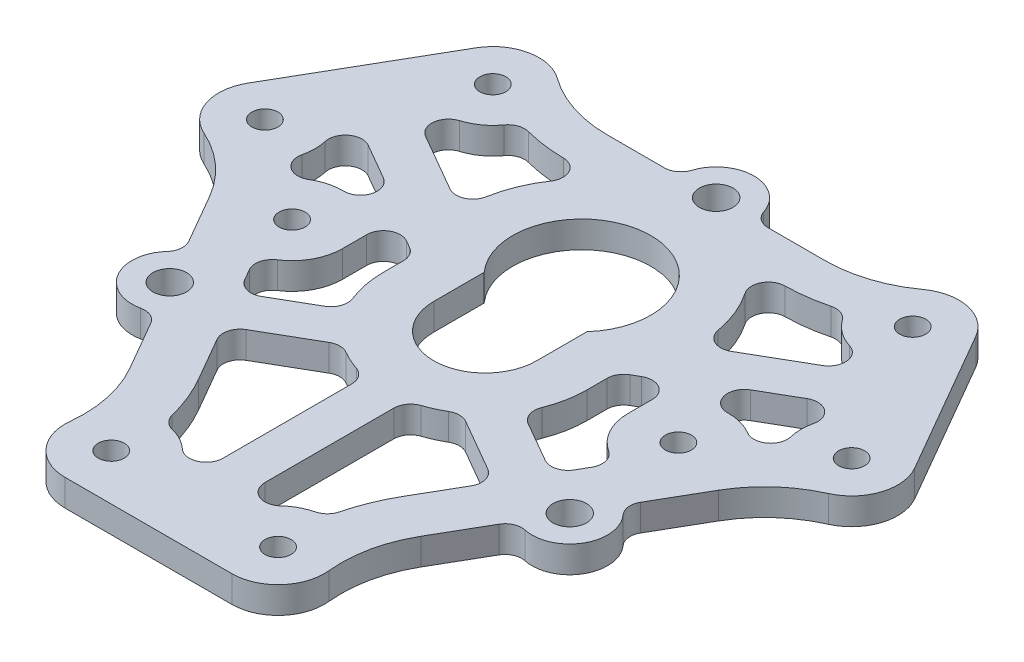
from build123d import *

# Parameters (mm, degrees)
SKETCH1_R           = 1.55
BOSS_EXTRUDE1_DEPTH = 3.175
BOSS_EXTRUDE2_DEPTH = 3.175
SKETCH6_3_R         = 2
CUT_EXTRUDE1_DEPTH  = 3.175
CUT_EXTRUDE2_DEPTH  = 3.175


with BuildPart() as part:
    # Sketch1 → Boss-Extrude1 (new body)
    with BuildSketch(Plane(origin=(0, 0, 0), x_dir=(1, 0, 0), z_dir=(0, 1, 0))):
        with BuildLine():
            Line((12.96622445, 27.5), (-12.96622445, 27.5))
            ThreePointArc((-12.96622445, 27.5), (-17.594676309, 28.231943602), (-21.771426072, 30.356342215))
            ThreePointArc((-21.771426072, 30.356342215), (-26.14607948, 31.282933613), (-29.763139721, 28.653667694))
            Line((-29.763139721, 28.653667694), (-39.696373995, 11.448801248))
            ThreePointArc((-39.696373995, 11.448801248), (-40.164854954, 7.001702233), (-37.17507656, 3.676436947))
            ThreePointArc((-37.17507656, 3.676436947), (-33.246918512, 1.121464854), (-30.298810829, -2.520920235))
            Line((-30.298810829, -2.520920235), (-17.332586379, -24.979079765))
            ThreePointArc((-17.332586379, -24.979079765), (-15.652242203, -29.353408456), (-15.403650488, -34.032779162))
            ThreePointArc((-15.403650488, -34.032779162), (-14.018775474, -38.284635845), (-9.933234274, -40.102468942))
            Line((-9.933234274, -40.102468942), (9.933234274, -40.102468942))
            ThreePointArc((9.933234274, -40.102468942), (14.018775474, -38.284635845), (15.403650488, -34.032779162))
            ThreePointArc((15.403650488, -34.032779162), (15.652242203, -29.353408456), (17.332586379, -24.979079765))
            Line((17.332586379, -24.979079765), (30.298810829, -2.520920235))
            ThreePointArc((30.298810829, -2.520920235), (33.246918512, 1.121464854), (37.17507656, 3.676436947))
            ThreePointArc((37.17507656, 3.676436947), (40.164854954, 7.001702233), (39.696373995, 11.448801248))
            Line((39.696373995, 11.448801248), (29.763139721, 28.653667694))
            ThreePointArc((29.763139721, 28.653667694), (26.14607948, 31.282933613), (21.771426072, 30.356342215))
            ThreePointArc((21.771426072, 30.356342215), (17.594676309, 28.231943602), (12.96622445, 27.5))
        make_face()
        with Locations((-9.933234274, -34.602468942)):
            Circle(SKETCH1_R, mode=Mode.SUBTRACT)
        with Locations((9.933234274, -34.602468942)):
            Circle(SKETCH1_R, mode=Mode.SUBTRACT)
        with Locations((-23, 0)):
            Circle(SKETCH1_R, mode=Mode.SUBTRACT)
        with Locations((-34.933234274, 8.698801248)):
            Circle(SKETCH1_R, mode=Mode.SUBTRACT)
        with BuildLine():
            ThreePointArc((6.125, 0), (0, -6.125), (-6.125, 0))
            Line((-6.125, 0), (-6.125, 6))
            ThreePointArc((-6.125, 6), (0, 19.714535499), (6.125, 6))
            Line((6.125, 6), (6.125, 0))
        make_face(mode=Mode.SUBTRACT)
        with Locations((-25, 25.903667694)):
            Circle(SKETCH1_R, mode=Mode.SUBTRACT)
        with Locations((23, 0)):
            Circle(SKETCH1_R, mode=Mode.SUBTRACT)
        with Locations((34.933234274, 8.698801248)):
            Circle(SKETCH1_R, mode=Mode.SUBTRACT)
        with Locations((25, 25.903667694)):
            Circle(SKETCH1_R, mode=Mode.SUBTRACT)
    extrude(amount=BOSS_EXTRUDE1_DEPTH)

    # Sketch6 → Boss-Extrude2 (add)
    with BuildSketch(Plane(origin=(0, 3.175, 0), x_dir=(1, 0, 0), z_dir=(0, 1, 0))):
        with BuildLine():
            ThreePointArc((-2, 27.5), (0, 29.5), (2, 27.5))
            Line((2, 27.5), (6.184658438, 27.5))
            ThreePointArc((6.184658438, 27.5), (5.007961628, 27.88278492), (4.281686611, 28.884615385))
            ThreePointArc((4.281686611, 28.884615385), (0, 32), (-4.281686611, 28.884615385))
            ThreePointArc((-4.281686611, 28.884615385), (-5.007961628, 27.88278492), (-6.184658438, 27.5))
            Line((-6.184658438, 27.5), (-2, 27.5))
        make_face()
        with BuildLine():
            ThreePointArc((-22.815698604, -15.482050808), (-25.547749412, -14.75), (-24.815698604, -12.017949192))
            Line((-24.815698604, -12.017949192), (-26.908027823, -8.393928679))
            ThreePointArc((-26.908027823, -8.393928679), (-26.651180883, -9.604370469), (-27.155654007, -10.734258316))
            ThreePointArc((-27.155654007, -10.734258316), (-27.712812921, -16), (-22.873967396, -18.150357069))
            ThreePointArc((-22.873967396, -18.150357069), (-21.643219255, -18.278414451), (-20.723369385, -19.106071321))
            Line((-20.723369385, -19.106071321), (-22.815698604, -15.482050808))
        make_face()
        with BuildLine():
            ThreePointArc((25.815698604, -13.75), (24.815698604, -15.482050808), (22.815698604, -15.482050808))
            Line((22.815698604, -15.482050808), (20.723369385, -19.106071321))
            ThreePointArc((20.723369385, -19.106071321), (21.643219255, -18.278414451), (22.873967396, -18.150357069))
            ThreePointArc((22.873967396, -18.150357069), (27.712812921, -16), (27.155654007, -10.734258316))
            ThreePointArc((27.155654007, -10.734258316), (26.651180883, -9.604370469), (26.908027823, -8.393928679))
            Line((26.908027823, -8.393928679), (24.815698604, -12.017949192))
            ThreePointArc((24.815698604, -12.017949192), (25.547749412, -12.75), (25.815698604, -13.75))
        make_face()
    extrude(amount=-BOSS_EXTRUDE2_DEPTH)

    # Sketch6_3 → Cut-Extrude1 (cut)
    with BuildSketch(Plane(origin=(0, 3.175, 0), x_dir=(1, 0, 0), z_dir=(0, 1, 0))):
        with Locations((0, 27.5)):
            Circle(SKETCH6_3_R)
        with Locations((23.815698604, -13.75)):
            Circle(SKETCH6_3_R)
        with Locations((-23.815698604, -13.75)):
            Circle(SKETCH6_3_R)
    extrude(amount=-CUT_EXTRUDE1_DEPTH, mode=Mode.SUBTRACT)

    # Sketch8 → Cut-Extrude2 (cut)
    with BuildSketch(Plane(origin=(0, 3.175, 0), x_dir=(1, 0, 0), z_dir=(0, 1, 0))):
        with BuildLine():
            ThreePointArc((-18.014934082, 23.14772543), (-15.625926996, 22.677639334), (-13.197500885, 22.501337264))
            ThreePointArc((-13.197500885, 22.501337264), (-11.44706524, 21.425848219), (-11.568049963, 19.374979054))
            ThreePointArc((-11.568049963, 19.374979054), (-12.96381501, 16.775318354), (-13.78372238, 13.940861134))
            ThreePointArc((-13.78372238, 13.940861134), (-14.908920662, 12.477814592), (-16.752825577, 12.558999702))
            Line((-16.752825577, 12.558999702), (-23.63134684, 16.530315806))
            ThreePointArc((-23.63134684, 16.530315806), (-24.618926237, 18.484915802), (-23.22351013, 20.172691883))
            ThreePointArc((-23.22351013, 20.172691883), (-21.502124547, 21.028745406), (-20.139853784, 22.385290403))
            ThreePointArc((-20.139853784, 22.385290403), (-19.195254644, 23.094987771), (-18.014934082, 23.14772543))
        make_face()
        with BuildLine():
            ThreePointArc((-29.097842321, 7.303021627), (-28.933338172, 8.663491751), (-29.081818699, 10.025803796))
            ThreePointArc((-29.081818699, 10.025803796), (-28.31786979, 12.078157634), (-26.13134684, 12.200188787))
            Line((-26.13134684, 12.200188787), (-21.854101966, 9.730720307))
            ThreePointArc((-21.854101966, 9.730720307), (-20.927050983, 7.463436365), (-22.890576475, 5.999002125))
            ThreePointArc((-22.890576475, 5.999002125), (-24.564350708, 5.792478473), (-26.114533752, 5.128321315))
            ThreePointArc((-26.114533752, 5.128321315), (-28.330833555, 5.221584528), (-29.097842321, 7.303021627))
        make_face()
        with BuildLine():
            ThreePointArc((-17, 2.886751346), (-16, 4.618802154), (-14, 4.618802154))
            Line((-14, 4.618802154), (-13.125, 4.113620668))
            ThreePointArc((-13.125, 4.113620668), (-12.392949192, 3.38156986), (-12.125, 2.38156986))
            Line((-12.125, 2.38156986), (-12.125, 0))
            ThreePointArc((-12.125, 0), (-11.905047907, -2.299012687), (-11.253171656, -4.514615451))
            ThreePointArc((-11.253171656, -4.514615451), (-11.219124876, -5.912740979), (-12.109364919, -6.991345096))
            Line((-12.109364919, -6.991345096), (-16.887495374, -9.75))
            ThreePointArc((-16.887495374, -9.75), (-18.405133464, -9.949800845), (-19.619546181, -9.017949192))
            Line((-19.619546181, -9.017949192), (-20.375025334, -7.709420916))
            ThreePointArc((-20.375025334, -7.709420916), (-20.587711347, -6.242517607), (-19.732230895, -5.032065687))
            ThreePointArc((-19.732230895, -5.032065687), (-17.727115845, -2.862986672), (-17, 0))
            Line((-17, 0), (-17, 2.886751346))
        make_face()
        with BuildLine():
            ThreePointArc((-5.858308569, -30.198495679), (-7.090344692, -29.318722276), (-8.503371348, -28.775334825))
            ThreePointArc((-8.503371348, -28.775334825), (-9.435726866, -28.252388095), (-9.965551857, -27.323924002))
            ThreePointArc((-9.965551857, -27.323924002), (-10.866584364, -24.576601814), (-12.136433956, -21.979079765))
            Line((-12.136433956, -21.979079765), (-15.119546181, -16.812177826))
            ThreePointArc((-15.119546181, -16.812177826), (-15.319347026, -15.294539736), (-14.387495374, -14.080127019))
            Line((-14.387495374, -14.080127019), (-8.124816175, -10.464367498))
            ThreePointArc((-8.124816175, -10.464367498), (-7.119714378, -10.196424812), (-6.115992646, -10.469491819))
            ThreePointArc((-6.115992646, -10.469491819), (-5.015599721, -11.038993815), (-3.862831858, -11.493222135))
            ThreePointArc((-3.862831858, -11.493222135), (-2.876063997, -12.221607456), (-2.5, -13.389011353))
            Line((-2.5, -13.389011353), (-2.5, -28.730504592))
            ThreePointArc((-2.5, -28.730504592), (-3.698943553, -30.563073436), (-5.858308569, -30.198495679))
        make_face()
        with BuildLine():
            ThreePointArc((6.115992646, -10.469491819), (5.015599721, -11.038993815), (3.862831858, -11.493222135))
            ThreePointArc((3.862831858, -11.493222135), (2.876063997, -12.221607456), (2.5, -13.389011353))
            Line((2.5, -13.389011353), (2.5, -28.730504592))
            ThreePointArc((2.5, -28.730504592), (3.698943553, -30.563073436), (5.858308569, -30.198495679))
            ThreePointArc((5.858308569, -30.198495679), (7.090344692, -29.318722276), (8.503371348, -28.775334825))
            ThreePointArc((8.503371348, -28.775334825), (9.435726866, -28.252388095), (9.965551857, -27.323924002))
            ThreePointArc((9.965551857, -27.323924002), (10.866584364, -24.576601814), (12.136433956, -21.979079765))
            Line((12.136433956, -21.979079765), (15.119546181, -16.812177826))
            ThreePointArc((15.119546181, -16.812177826), (15.319347026, -15.294539736), (14.387495374, -14.080127019))
            Line((14.387495374, -14.080127019), (8.124816175, -10.464367498))
            ThreePointArc((8.124816175, -10.464367498), (7.119714378, -10.196424812), (6.115992646, -10.469491819))
        make_face()
        with BuildLine():
            Line((14, 4.618802154), (13.125, 4.113620668))
            ThreePointArc((13.125, 4.113620668), (12.392949192, 3.38156986), (12.125, 2.38156986))
            Line((12.125, 2.38156986), (12.125, 0))
            ThreePointArc((12.125, 0), (11.905047907, -2.299012687), (11.253171656, -4.514615451))
            ThreePointArc((11.253171656, -4.514615451), (11.219124876, -5.912740979), (12.109364919, -6.991345096))
            Line((12.109364919, -6.991345096), (16.887495374, -9.75))
            ThreePointArc((16.887495374, -9.75), (18.405133464, -9.949800845), (19.619546181, -9.017949192))
            Line((19.619546181, -9.017949192), (20.375025334, -7.709420916))
            ThreePointArc((20.375025334, -7.709420916), (20.587711347, -6.242517607), (19.732230895, -5.032065687))
            ThreePointArc((19.732230895, -5.032065687), (17.727115845, -2.862986672), (17, 0))
            Line((17, 0), (17, 2.886751346))
            ThreePointArc((17, 2.886751346), (16, 4.618802154), (14, 4.618802154))
        make_face()
        with BuildLine():
            ThreePointArc((22.890576475, 5.999002125), (20.927050983, 7.463436365), (21.854101966, 9.730720307))
            Line((21.854101966, 9.730720307), (26.13134684, 12.200188787))
            ThreePointArc((26.13134684, 12.200188787), (28.31786979, 12.078157634), (29.081818699, 10.025803796))
            ThreePointArc((29.081818699, 10.025803796), (28.933338172, 8.663491751), (29.097842321, 7.303021627))
            ThreePointArc((29.097842321, 7.303021627), (28.330833555, 5.221584528), (26.114533752, 5.128321315))
            ThreePointArc((26.114533752, 5.128321315), (24.564350708, 5.792478473), (22.890576475, 5.999002125))
        make_face()
        with BuildLine():
            ThreePointArc((11.568049963, 19.374979054), (11.44706524, 21.425848219), (13.197500885, 22.501337264))
            ThreePointArc((13.197500885, 22.501337264), (15.625926996, 22.677639334), (18.014934082, 23.14772543))
            ThreePointArc((18.014934082, 23.14772543), (19.195254644, 23.094987771), (20.139853784, 22.385290403))
            ThreePointArc((20.139853784, 22.385290403), (21.502124547, 21.028745406), (23.22351013, 20.172691883))
            ThreePointArc((23.22351013, 20.172691883), (24.618926237, 18.484915802), (23.63134684, 16.530315806))
            Line((23.63134684, 16.530315806), (16.752825577, 12.558999702))
            ThreePointArc((16.752825577, 12.558999702), (14.908920662, 12.477814592), (13.78372238, 13.940861134))
            ThreePointArc((13.78372238, 13.940861134), (12.96381501, 16.775318354), (11.568049963, 19.374979054))
        make_face()
    extrude(amount=-CUT_EXTRUDE2_DEPTH, mode=Mode.SUBTRACT)


solid = part.part
